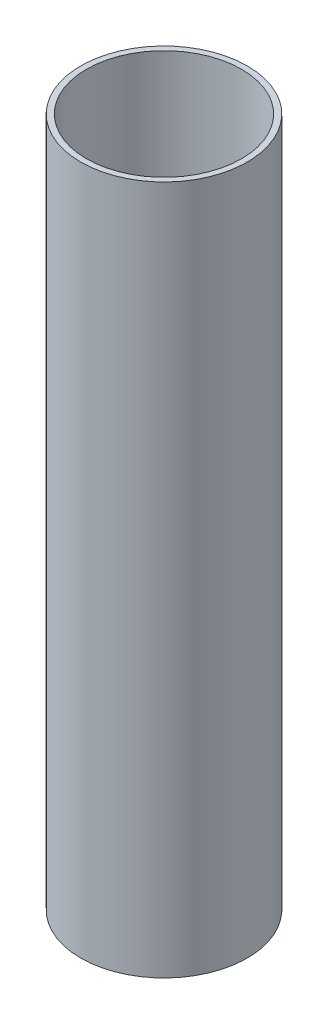
from build123d import *

# Parameters (mm, degrees)
SKETCH1_R           = 29
SKETCH1_R_2         = 27
BOSS_EXTRUDE1_DEPTH = 240


with BuildPart() as part:
    # Sketch1 → Boss-Extrude1 (new body)
    with BuildSketch(Plane(origin=(0, 0, 0), x_dir=(1, 0, 0), z_dir=(0, 1, 0))):
        Circle(SKETCH1_R)
        Circle(SKETCH1_R_2, mode=Mode.SUBTRACT)
    extrude(amount=BOSS_EXTRUDE1_DEPTH)


solid = part.part
